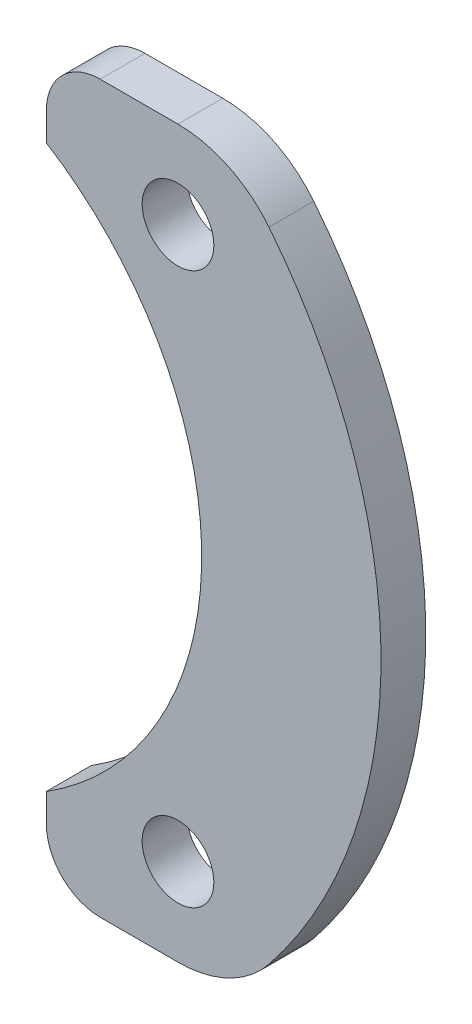
from build123d import *

# Parameters (mm, degrees)
SKETCH2_R           = 2
BOSS_EXTRUDE1_DEPTH = 2.5


with BuildPart() as part:
    # Sketch2 → Boss-Extrude1 (new body)
    with BuildSketch(Plane.XY):
        with BuildLine():
            Line((17.177810632, 20.25), (12.833062768, 20.25))
            ThreePointArc((12.833062768, 20.25), (10.711742424, 19.371320344), (9.833062768, 17.25))
            Line((9.833062768, 17.25), (9.833062768, 15.670382146))
            ThreePointArc((9.833062768, 15.670382146), (18.5, 0), (9.833062768, -15.670382146))
            Line((9.833062768, -15.670382146), (9.833062768, -17.25))
            ThreePointArc((9.833062768, -17.25), (10.711742424, -19.371320344), (12.833062768, -20.25))
            Line((12.833062768, -20.25), (17.177810632, -20.25))
            ThreePointArc((17.177810632, -20.25), (19.992731544, -19.608858273), (22.252340685, -17.811913926))
            ThreePointArc((22.252340685, -17.811913926), (28.503174274, 0), (22.252340685, 17.811913926))
            ThreePointArc((22.252340685, 17.811913926), (19.992731544, 19.608858273), (17.177810632, 20.25))
        make_face()
        with Locations((17.177810632, -15.391359244)):
            Circle(SKETCH2_R, mode=Mode.SUBTRACT)
        with Locations((17.177810632, 15.391359244)):
            Circle(SKETCH2_R, mode=Mode.SUBTRACT)
    extrude(amount=BOSS_EXTRUDE1_DEPTH)


solid = part.part
